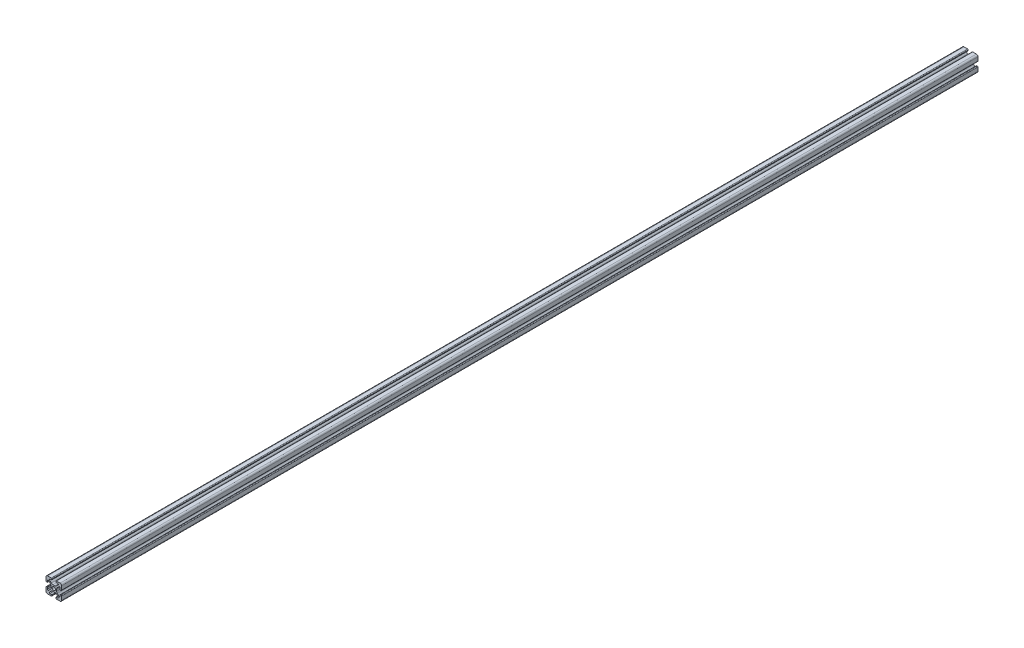
from build123d import *

# Parameters (mm, degrees)
SKETCH1_R           = 2.1463
BOSS_EXTRUDE1_DEPTH = 585


with BuildPart() as part:
    # Sketch1 → Boss-Extrude1 (new body, symmetric)
    with BuildSketch(Plane.XY):
        with BuildLine():
            Line((-9.9949, 7.9883), (-9.9949, 3.2893))
            ThreePointArc((-9.9949, 3.2893), (-9.76427588, 2.73252412), (-9.2075, 2.5019))
            Line((-9.2075, 2.5019), (-8.4963, 2.5019))
            ThreePointArc((-8.4963, 2.5019), (-8.280773853, 2.591173853), (-8.1915, 2.8067))
            Line((-8.1915, 2.8067), (-8.1915, 4.9149))
            ThreePointArc((-8.1915, 4.9149), (-7.674065253, 5.689295824), (-6.760603096, 5.507596904))
            Line((-6.760603096, 5.507596904), (-4.505765747, 3.252759555))
            ThreePointArc((-4.505765747, 3.252759555), (-3.856054457, 2.280397894), (-3.627906192, 1.133419111))
            Line((-3.627906192, 1.133419111), (-3.627906192, -1.133419111))
            ThreePointArc((-3.627906192, -1.133419111), (-3.856054457, -2.280397894), (-4.505765747, -3.252759555))
            Line((-4.505765747, -3.252759555), (-6.760603096, -5.507596904))
            ThreePointArc((-6.760603096, -5.507596904), (-7.674065253, -5.689295824), (-8.1915, -4.9149))
            Line((-8.1915, -4.9149), (-8.1915, -2.8067))
            ThreePointArc((-8.1915, -2.8067), (-8.280773853, -2.591173853), (-8.4963, -2.5019))
            Line((-8.4963, -2.5019), (-9.2075, -2.5019))
            ThreePointArc((-9.2075, -2.5019), (-9.76427588, -2.73252412), (-9.9949, -3.2893))
            Line((-9.9949, -3.2893), (-9.9949, -7.9883))
            ThreePointArc((-9.9949, -7.9883), (-9.407180467, -9.407180467), (-7.9883, -9.9949))
            Line((-7.9883, -9.9949), (-3.2893, -9.9949))
            ThreePointArc((-3.2893, -9.9949), (-2.73252412, -9.76427588), (-2.5019, -9.2075))
            Line((-2.5019, -9.2075), (-2.5019, -8.4963))
            ThreePointArc((-2.5019, -8.4963), (-2.591173853, -8.280773853), (-2.8067, -8.1915))
            Line((-2.8067, -8.1915), (-4.9149, -8.1915))
            ThreePointArc((-4.9149, -8.1915), (-5.689295824, -7.674065253), (-5.507596904, -6.760603096))
            Line((-5.507596904, -6.760603096), (-3.252759555, -4.505765747))
            ThreePointArc((-3.252759555, -4.505765747), (-2.280397894, -3.856054457), (-1.133419111, -3.627906192))
            Line((-1.133419111, -3.627906192), (1.133419111, -3.627906192))
            ThreePointArc((1.133419111, -3.627906192), (2.280397894, -3.856054457), (3.252759555, -4.505765747))
            Line((3.252759555, -4.505765747), (5.507596904, -6.760603096))
            ThreePointArc((5.507596904, -6.760603096), (5.689295824, -7.674065253), (4.9149, -8.1915))
            Line((4.9149, -8.1915), (2.8067, -8.1915))
            ThreePointArc((2.8067, -8.1915), (2.591173853, -8.280773853), (2.5019, -8.4963))
            Line((2.5019, -8.4963), (2.5019, -9.2075))
            ThreePointArc((2.5019, -9.2075), (2.73252412, -9.76427588), (3.2893, -9.9949))
            Line((3.2893, -9.9949), (7.9883, -9.9949))
            ThreePointArc((7.9883, -9.9949), (9.407180467, -9.407180467), (9.9949, -7.9883))
            Line((9.9949, -7.9883), (9.9949, -3.2893))
            ThreePointArc((9.9949, -3.2893), (9.76427588, -2.73252412), (9.2075, -2.5019))
            Line((9.2075, -2.5019), (8.4963, -2.5019))
            ThreePointArc((8.4963, -2.5019), (8.280773853, -2.591173853), (8.1915, -2.8067))
            Line((8.1915, -2.8067), (8.1915, -4.9149))
            ThreePointArc((8.1915, -4.9149), (7.674065253, -5.689295824), (6.760603096, -5.507596904))
            Line((6.760603096, -5.507596904), (4.505765747, -3.252759555))
            ThreePointArc((4.505765747, -3.252759555), (3.856054457, -2.280397894), (3.627906192, -1.133419111))
            Line((3.627906192, -1.133419111), (3.627906192, 1.133419111))
            ThreePointArc((3.627906192, 1.133419111), (3.856054457, 2.280397894), (4.505765747, 3.252759555))
            Line((4.505765747, 3.252759555), (6.760603096, 5.507596904))
            ThreePointArc((6.760603096, 5.507596904), (7.674065253, 5.689295824), (8.1915, 4.9149))
            Line((8.1915, 4.9149), (8.1915, 2.8067))
            ThreePointArc((8.1915, 2.8067), (8.280773853, 2.591173853), (8.4963, 2.5019))
            Line((8.4963, 2.5019), (9.2075, 2.5019))
            ThreePointArc((9.2075, 2.5019), (9.76427588, 2.73252412), (9.9949, 3.2893))
            Line((9.9949, 3.2893), (9.9949, 7.9883))
            ThreePointArc((9.9949, 7.9883), (9.407180467, 9.407180467), (7.9883, 9.9949))
            Line((7.9883, 9.9949), (3.2893, 9.9949))
            ThreePointArc((3.2893, 9.9949), (2.73252412, 9.76427588), (2.5019, 9.2075))
            Line((2.5019, 9.2075), (2.5019, 8.4963))
            ThreePointArc((2.5019, 8.4963), (2.591173853, 8.280773853), (2.8067, 8.1915))
            Line((2.8067, 8.1915), (4.9149, 8.1915))
            ThreePointArc((4.9149, 8.1915), (5.689295824, 7.674065253), (5.507596904, 6.760603096))
            Line((5.507596904, 6.760603096), (3.252759555, 4.505765747))
            ThreePointArc((3.252759555, 4.505765747), (2.280397894, 3.856054457), (1.133419111, 3.627906192))
            Line((1.133419111, 3.627906192), (-1.133419111, 3.627906192))
            ThreePointArc((-1.133419111, 3.627906192), (-2.280397894, 3.856054457), (-3.252759555, 4.505765747))
            Line((-3.252759555, 4.505765747), (-5.507596904, 6.760603096))
            ThreePointArc((-5.507596904, 6.760603096), (-5.689295824, 7.674065253), (-4.9149, 8.1915))
            Line((-4.9149, 8.1915), (-2.8067, 8.1915))
            ThreePointArc((-2.8067, 8.1915), (-2.591173853, 8.280773853), (-2.5019, 8.4963))
            Line((-2.5019, 8.4963), (-2.5019, 9.2075))
            ThreePointArc((-2.5019, 9.2075), (-2.73252412, 9.76427588), (-3.2893, 9.9949))
            Line((-3.2893, 9.9949), (-7.9883, 9.9949))
            ThreePointArc((-7.9883, 9.9949), (-9.407180467, 9.407180467), (-9.9949, 7.9883))
        make_face()
        Circle(SKETCH1_R, mode=Mode.SUBTRACT)
    extrude(amount=BOSS_EXTRUDE1_DEPTH, both=True)


solid = part.part
